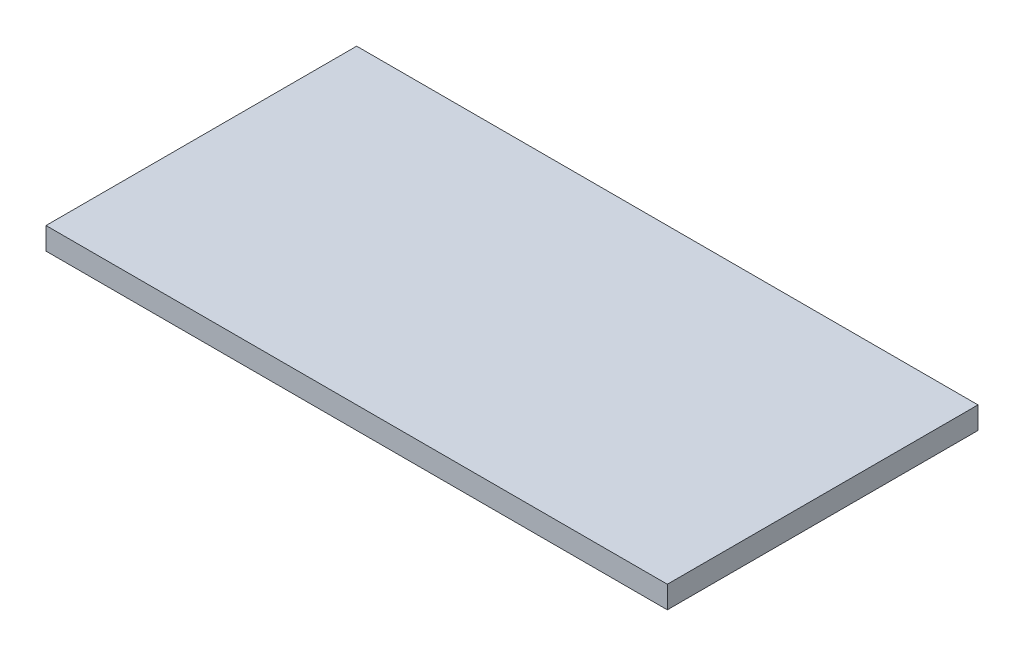
from build123d import *

# Parameters (mm, degrees)
SKETCH1_W           = 88.9
SKETCH1_H           = 44.45
BOSS_EXTRUDE1_DEPTH = 3.175


with BuildPart() as part:
    # Sketch1 → Boss-Extrude1 (new body)
    with BuildSketch(Plane(origin=(0, 0, 0), x_dir=(1, 0, 0), z_dir=(0, 1, 0))):
        with Locations((44.45, -22.225)):
            Rectangle(SKETCH1_W, SKETCH1_H)
    extrude(amount=BOSS_EXTRUDE1_DEPTH)


solid = part.part
